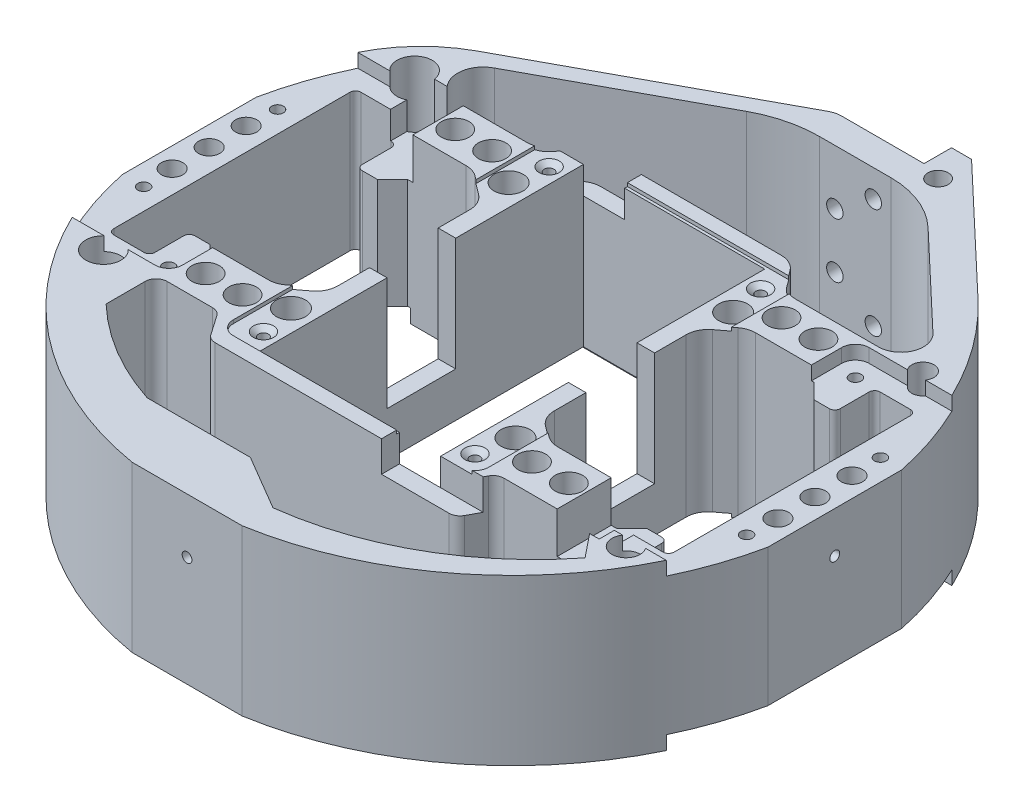
from build123d import *

# Parameters (mm, degrees)
SKETCH1_R             = 2.356484411
SKETCH1_R_2           = 3.356538595
SKETCH1_R_3           = 3.175
SKETCH1_R_4           = 4.064709562
SKETCH1_R_5           = 2.555437721
SKETCH1_R_6           = 3.242334338
SKETCH1_R_7           = 2.462755239
BOSS_EXTRUDE1_DEPTH   = 38.1
SKETCH2_W             = 4.064
SKETCH2_H             = 15.875
CUT_EXTRUDE1_DEPTH    = 26.9875
CUT_EXTRUDE2_DEPTH    = 3.175
SKETCH4_R             = 1.35255
CUT_EXTRUDE3_DEPTH    = 6.35
SKETCH5_W             = 10.883984269
SKETCH5_H             = 18.972538828
CUT_EXTRUDE4_DEPTH    = 6.35
CUT_EXTRUDE7_DEPTH    = 7.112
CUT_EXTRUDE8_REACH    = 153.334
SKETCH10_R            = 1.89865
SKETCH11_R            = 1.1303
CUT_EXTRUDE9_DEPTH    = 9.525
SKETCH12_R            = 1.1303
CUT_EXTRUDE10_DEPTH   = 9.525
CUT_EXTRUDE11_DEPTH   = 0.79375
SKETCH6_R             = 1.1303
CUT_EXTRUDE5_DEPTH    = 12.7
CHAMFER1_SIZE         = 1.19507
CHAMFER1_SIZE2        = 1.038858502
CHAMFER1_PART_2_SIZE  = 1.19507
CHAMFER1_PART_2_SIZE2 = 1.038858502
CHAMFER1_PART_3_SIZE  = 1.19507
CHAMFER1_PART_3_SIZE2 = 1.038858502
CHAMFER1_PART_4_SIZE  = 1.19507
CHAMFER1_PART_4_SIZE2 = 1.038858502
CHAMFER2_SIZE         = 1.19507
CHAMFER2_SIZE2        = 1.038858502
CHAMFER2_PART_2_SIZE  = 1.19507
CHAMFER2_PART_2_SIZE2 = 1.038858502
CHAMFER2_PART_3_SIZE  = 1.19507
CHAMFER2_PART_3_SIZE2 = 1.038858502
CHAMFER2_PART_4_SIZE  = 1.19507
CHAMFER2_PART_4_SIZE2 = 1.038858502


with BuildPart() as part:
    # Sketch1 → Boss-Extrude1 (new body)
    with BuildSketch(Plane(origin=(0, 0, 0), x_dir=(1, 0, 0), z_dir=(0, 1, 0))):
        with BuildLine():
            Line((-74.6125, 15.473036022), (-74.6125, -15.473036022))
            ThreePointArc((-74.6125, -15.473036022), (-52.874683743, -54.86991725), (-12.7, -75.134213245))
            Line((-12.7, -75.134213245), (12.7, -75.134213245))
            ThreePointArc((12.7, -75.134213245), (52.874683743, -54.86991725), (74.6125, -15.473036022))
            Line((74.6125, -15.473036022), (74.6125, 15.473036022))
            ThreePointArc((74.6125, 15.473036022), (66.568680107, 37.081677804), (52.429845716, 55.295128883))
            Line((52.429845716, 55.295128883), (23.6855, 82.55))
            Line((23.6855, 82.55), (19.05, 82.55))
            Line((19.05, 82.55), (19.05, 76.2))
            Line((19.05, 76.2), (0, 76.2))
            ThreePointArc((0, 76.2), (-1.309576606, 76.036760248), (-2.539006662, 75.557031324))
            Line((-2.539006662, 75.557031324), (-55.150410299, 47.084918442))
            ThreePointArc((-55.150410299, 47.084918442), (-63.168001103, 40.936392006), (-68.874977996, 32.598733198))
            ThreePointArc((-68.874977996, 32.598733198), (-72.252933929, 24.206477205), (-74.6125, 15.473036022))
        make_face()
        with Locations((23.6855, 74.812542953)):
            Circle(SKETCH1_R, mode=Mode.SUBTRACT)
        with Locations((-25.953983408, 25.159074147)):
            Circle(SKETCH1_R_2, mode=Mode.SUBTRACT)
        with Locations((-41.987680119, 28.850105121)):
            Circle(SKETCH1_R_3, mode=Mode.SUBTRACT)
        with Locations((41.987680119, 28.850105121)):
            Circle(SKETCH1_R_3, mode=Mode.SUBTRACT)
        with Locations((-41.987680119, -28.850105121)):
            Circle(SKETCH1_R_3, mode=Mode.SUBTRACT)
        with Locations((41.987680119, -28.850105121)):
            Circle(SKETCH1_R_3, mode=Mode.SUBTRACT)
        with Locations((-33.451838253, 28.850105121)):
            Circle(SKETCH1_R_3, mode=Mode.SUBTRACT)
        with Locations((33.451838253, 28.850105121)):
            Circle(SKETCH1_R_3, mode=Mode.SUBTRACT)
        with Locations((-33.451838253, -28.850105121)):
            Circle(SKETCH1_R_3, mode=Mode.SUBTRACT)
        with Locations((33.451838253, -28.850105121)):
            Circle(SKETCH1_R_3, mode=Mode.SUBTRACT)
        with Locations((-58.499626731, 35.97459363)):
            Circle(SKETCH1_R_4, mode=Mode.SUBTRACT)
        with Locations((60.460006294, 34.52310187)):
            Circle(SKETCH1_R_5, mode=Mode.SUBTRACT)
        with Locations((-58.499626731, -35.97459363)):
            Circle(SKETCH1_R_4, mode=Mode.SUBTRACT)
        with Locations((61.236723994, -34.882223147)):
            Circle(SKETCH1_R_6, mode=Mode.SUBTRACT)
        with Locations((25.953983408, 25.159074147)):
            Circle(SKETCH1_R_2, mode=Mode.SUBTRACT)
        with Locations((25.953983408, -25.159074147)):
            Circle(SKETCH1_R_2, mode=Mode.SUBTRACT)
        with Locations((-25.953983408, -25.159074147)):
            Circle(SKETCH1_R_2, mode=Mode.SUBTRACT)
        with Locations((70.02564652, 8.562540674)):
            Circle(SKETCH1_R_7, mode=Mode.SUBTRACT)
        with Locations((-70.02564652, 8.562540674)):
            Circle(SKETCH1_R_7, mode=Mode.SUBTRACT)
        with Locations((70.02564652, -8.562540674)):
            Circle(SKETCH1_R_7, mode=Mode.SUBTRACT)
        with Locations((-70.02564652, -8.562540674)):
            Circle(SKETCH1_R_7, mode=Mode.SUBTRACT)
        with Locations((-70.02564652, 0)):
            Circle(SKETCH1_R_7, mode=Mode.SUBTRACT)
        with Locations((70.02564652, 0)):
            Circle(SKETCH1_R_7, mode=Mode.SUBTRACT)
        Polygon((20.955, 37.465), (-20.955, 37.465), (-20.955, 0), (-20.955, -37.465), (20.955, -37.465), (20.955, 0), align=None, mode=Mode.SUBTRACT)
        with BuildLine():
            Line((-53.975, 19.3675), (-50.4825, 19.3675))
            Line((-50.4825, 19.3675), (-46.99, 22.86))
            Line((-46.99, 22.86), (-33.451838253, 22.86))
            ThreePointArc((-33.451838253, 22.86), (-31.838145049, 22.596886364), (-30.391611171, 21.834800884))
            Line((-30.391611171, 21.834800884), (-27.038772918, 19.304356919))
            ThreePointArc((-27.038772918, 19.304356919), (-25.551893581, 17.514555641), (-25.019, 15.249556036))
            Line((-25.019, 15.249556036), (-25.019, 0))
            Line((-25.019, 0), (-25.019, -15.249556036))
            ThreePointArc((-25.019, -15.249556036), (-25.551893581, -17.514555641), (-27.038772918, -19.304356919))
            Line((-27.038772918, -19.304356919), (-30.391611171, -21.834800884))
            ThreePointArc((-30.391611171, -21.834800884), (-31.838145049, -22.596886364), (-33.451838253, -22.86))
            Line((-33.451838253, -22.86), (-46.99, -22.86))
            Line((-46.99, -22.86), (-50.4825, -19.3675))
            Line((-50.4825, -19.3675), (-53.975, -19.3675))
            ThreePointArc((-53.975, -19.3675), (-54.873025612, -19.739474388), (-55.245, -20.6375))
            Line((-55.245, -20.6375), (-55.245, -27.305))
            ThreePointArc((-55.245, -27.305), (-55.616974388, -28.203025612), (-56.515, -28.575))
            Line((-56.515, -28.575), (-63.5, -28.575))
            ThreePointArc((-63.5, -28.575), (-64.398025612, -28.203025612), (-64.77, -27.305))
            Line((-64.77, -27.305), (-64.77, 27.305))
            ThreePointArc((-64.77, 27.305), (-64.398025612, 28.203025612), (-63.5, 28.575))
            Line((-63.5, 28.575), (-56.515, 28.575))
            ThreePointArc((-56.515, 28.575), (-55.616974388, 28.203025612), (-55.245, 27.305))
            Line((-55.245, 27.305), (-55.245, 20.6375))
            ThreePointArc((-55.245, 20.6375), (-54.873025612, 19.739474388), (-53.975, 19.3675))
        make_face(mode=Mode.SUBTRACT)
        with BuildLine():
            Line((64.77, 27.305), (64.77, -27.305))
            ThreePointArc((64.77, -27.305), (64.398025612, -28.203025612), (63.5, -28.575))
            Line((63.5, -28.575), (56.515, -28.575))
            ThreePointArc((56.515, -28.575), (55.616974388, -28.203025612), (55.245, -27.305))
            Line((55.245, -27.305), (55.245, -20.6375))
            ThreePointArc((55.245, -20.6375), (54.873025612, -19.739474388), (53.975, -19.3675))
            Line((53.975, -19.3675), (50.4825, -19.3675))
            Line((50.4825, -19.3675), (46.99, -22.86))
            Line((46.99, -22.86), (33.451838253, -22.86))
            ThreePointArc((33.451838253, -22.86), (31.838145049, -22.596886364), (30.391611171, -21.834800884))
            Line((30.391611171, -21.834800884), (27.038772918, -19.304356919))
            ThreePointArc((27.038772918, -19.304356919), (25.551893581, -17.514555641), (25.019, -15.249556036))
            Line((25.019, -15.249556036), (25.019, 0))
            Line((25.019, 0), (25.019, 15.249556036))
            ThreePointArc((25.019, 15.249556036), (25.551893581, 17.514555641), (27.038772918, 19.304356919))
            Line((27.038772918, 19.304356919), (30.391611171, 21.834800884))
            ThreePointArc((30.391611171, 21.834800884), (31.838145049, 22.596886364), (33.451838253, 22.86))
            Line((33.451838253, 22.86), (46.99, 22.86))
            Line((46.99, 22.86), (50.4825, 19.3675))
            Line((50.4825, 19.3675), (53.975, 19.3675))
            ThreePointArc((53.975, 19.3675), (54.873025612, 19.739474388), (55.245, 20.6375))
            Line((55.245, 20.6375), (55.245, 27.305))
            ThreePointArc((55.245, 27.305), (55.616974388, 28.203025612), (56.515, 28.575))
            Line((56.515, 28.575), (63.5, 28.575))
            ThreePointArc((63.5, 28.575), (64.398025612, 28.203025612), (64.77, 27.305))
        make_face(mode=Mode.SUBTRACT)
        with BuildLine():
            Line((-20.845950883, 41.338131188), (0, 41.338131188))
            Line((0, 41.338131188), (20.900876069, 41.338131188))
            ThreePointArc((20.900876069, 41.338131188), (23.189592711, 40.793346302), (24.987420284, 39.275838327))
            Line((24.987420284, 39.275838327), (27.196988383, 36.283666683))
            ThreePointArc((27.196988383, 36.283666683), (28.994815956, 34.766158708), (31.283532598, 34.221373822))
            Line((31.283532598, 34.221373822), (50.45628088, 34.221373822))
            ThreePointArc((50.45628088, 34.221373822), (55.31708187, 37.516208085), (54.056832983, 43.251632379))
            Line((54.056832983, 43.251632379), (32.348707377, 63.834886263))
            ThreePointArc((32.348707377, 63.834886263), (25.730530949, 68.068574663), (18.014985698, 69.550039535))
            Line((18.014985698, 69.550039535), (1.55163213, 69.550039535))
            ThreePointArc((1.55163213, 69.550039535), (-5.413950327, 68.681774216), (-11.953236682, 66.130116403))
            Line((-11.953236682, 66.130116403), (-49.707341043, 45.69844101))
            ThreePointArc((-49.707341043, 45.69844101), (-52.830230484, 39.073656263), (-47.091531492, 34.52310187))
            Line((-47.091531492, 34.52310187), (-31.086999544, 34.52310187))
            ThreePointArc((-31.086999544, 34.52310187), (-28.840846685, 35.046656179), (-27.057679262, 36.509402133))
            Line((-27.057679262, 36.509402133), (-24.875271165, 39.351830925))
            ThreePointArc((-24.875271165, 39.351830925), (-23.092103742, 40.814576878), (-20.845950883, 41.338131188))
        make_face(mode=Mode.SUBTRACT)
        with BuildLine():
            Line((-23.854336738, -60.495536567), (0, -60.495536567))
            Line((0, -60.495536567), (12.7, -67.96894498))
            ThreePointArc((12.7, -67.96894498), (38.322472705, -59.497281046), (58.80689112, -41.928308409))
            Line((58.80689112, -41.928308409), (54.275996481, -36.293661738))
            ThreePointArc((54.275996481, -36.293661738), (53.394000982, -35.594661364), (52.296567671, -35.345346879))
            Line((52.296567671, -35.345346879), (33.457769344, -35.345346879))
            ThreePointArc((33.457769344, -35.345346879), (32.159314658, -35.702317921), (31.225829045, -36.672893786))
            Line((31.225829045, -36.672893786), (29.270713217, -40.271962344))
            ThreePointArc((29.270713217, -40.271962344), (28.337227604, -41.242538208), (27.038772918, -41.599509251))
            Line((27.038772918, -41.599509251), (-27.038772918, -41.599509251))
            ThreePointArc((-27.038772918, -41.599509251), (-28.216614381, -41.30990688), (-29.125868694, -40.507138769))
            Line((-29.125868694, -40.507138769), (-32.269685191, -35.97459363))
            ThreePointArc((-32.269685191, -35.97459363), (-33.178939505, -35.171825519), (-34.356780968, -34.882223147))
            Line((-34.356780968, -34.882223147), (-44.859278162, -34.882223147))
            ThreePointArc((-44.859278162, -34.882223147), (-46.655329386, -35.626171923), (-47.399278162, -37.422223147))
            Line((-47.399278162, -37.422223147), (-47.399278162, -46.454771748))
            ThreePointArc((-47.399278162, -46.454771748), (-36.419314032, -54.804107481), (-23.854336738, -60.495536567))
        make_face(mode=Mode.SUBTRACT)
    extrude(amount=BOSS_EXTRUDE1_DEPTH)

    # Sketch2 → Cut-Extrude1 (cut)
    with BuildSketch(Plane(origin=(0, 38.1, 0), x_dir=(1, 0, 0), z_dir=(0, 1, 0))):
        with Locations((-22.987, 0)):
            Rectangle(SKETCH2_W, SKETCH2_H)
        with Locations((22.987, 0)):
            Rectangle(SKETCH2_W, SKETCH2_H)
    extrude(amount=-CUT_EXTRUDE1_DEPTH, mode=Mode.SUBTRACT)

    # Sketch3 → Cut-Extrude2 (cut)
    with BuildSketch(Plane(origin=(0, 38.1, 0), x_dir=(1, 0, 0), z_dir=(0, 1, 0))):
        with BuildLine():
            Line((-49.53, 33.02), (-80.011418761, 33.02))
            Line((-80.011418761, 33.02), (-80.011418761, -33.02))
            Line((-80.011418761, -33.02), (-49.53, -33.02))
            ThreePointArc((-49.53, -33.02), (-47.28493597, -32.09006403), (-46.355, -29.845))
            Line((-46.355, -29.845), (-46.355, 29.845))
            ThreePointArc((-46.355, 29.845), (-47.28493597, 32.09006403), (-49.53, 33.02))
        make_face()
        with BuildLine():
            Line((80.011418761, 33.02), (80.011418761, -33.02))
            Line((80.011418761, -33.02), (49.53, -33.02))
            ThreePointArc((49.53, -33.02), (47.28493597, -32.09006403), (46.355, -29.845))
            Line((46.355, -29.845), (46.355, 29.845))
            ThreePointArc((46.355, 29.845), (47.28493597, 32.09006403), (49.53, 33.02))
            Line((49.53, 33.02), (80.011418761, 33.02))
        make_face()
    cut_extrude2 = extrude(amount=-CUT_EXTRUDE2_DEPTH, mode=Mode.SUBTRACT)

    # Sketch4 → Cut-Extrude3 (cut)
    with BuildSketch(Plane(origin=(0, 34.925, 0), x_dir=(1, 0, 0), z_dir=(0, 1, 0))):
        with Locations((-50.8, 28.575)):
            Circle(SKETCH4_R)
        with Locations((-69.69125, 15.473036022)):
            Circle(SKETCH4_R)
        with Locations((69.69125, 15.473036022)):
            Circle(SKETCH4_R)
        with Locations((50.8, 28.575)):
            Circle(SKETCH4_R)
        with Locations((50.8, -28.575)):
            Circle(SKETCH4_R)
        with Locations((69.69125, -15.473036022)):
            Circle(SKETCH4_R)
        with Locations((-69.69125, -15.473036022)):
            Circle(SKETCH4_R)
        with Locations((-50.8, -28.575)):
            Circle(SKETCH4_R)
    cut_extrude3 = extrude(amount=-CUT_EXTRUDE3_DEPTH, mode=Mode.SUBTRACT)

    # Mirror1: Cut-Extrude2, Cut-Extrude3 across plane
    add(cut_extrude2.mirror(Plane.ZX.offset(19.05)), mode=Mode.SUBTRACT)
    add(cut_extrude3.mirror(Plane.ZX.offset(19.05)), mode=Mode.SUBTRACT)

    # Sketch5 → Cut-Extrude4 (cut, symmetric)
    with BuildSketch(Plane(origin=(0, 34.925, 0), x_dir=(1, 0, 0), z_dir=(0, 1, 0))):
        with Locations((-51.228437622, 27.038665643)):
            Rectangle(SKETCH5_W, SKETCH5_H)
        with Locations((51.228437622, -27.038665643)):
            Rectangle(SKETCH5_W, SKETCH5_H)
    extrude(amount=CUT_EXTRUDE4_DEPTH, both=True, mode=Mode.SUBTRACT)

    # Sketch9 → Cut-Extrude7 (cut)
    with BuildSketch(Plane(origin=(0, 38.1, 0), x_dir=(1, 0, 0), z_dir=(0, 1, 0))):
        Polygon((-20.955, 34.326574642), (-11.43, 34.326574642), (-11.43, 45.377122901), (-20.955, 45.377122901), (-29.461924573, 45.377122901), (-29.461924573, 37.465), (-20.955, 37.465), align=None)
        Polygon((20.955, -34.326574642), (11.43, -34.326574642), (11.43, -45.377122901), (20.955, -45.377122901), (32.397962239, -45.377122901), (32.397962239, -37.465), (20.955, -37.465), align=None)
    extrude(amount=-CUT_EXTRUDE7_DEPTH, mode=Mode.SUBTRACT)

    # Sketch10 → Cut-Extrude8 (cut, up to next)
    with BuildSketch(Plane(origin=(0, 0, -76.2), x_dir=(-1, 0, 0), z_dir=(0, 0, -1)), mode=Mode.PRIVATE) as cut_extrude8_sk1:
        with Locations((-13.97, 31.75)):
            Circle(SKETCH10_R)
    cut_extrude8_tool1 = extrude(cut_extrude8_sk1.sketch, amount=-CUT_EXTRUDE8_REACH, mode=Mode.PRIVATE) & part.part
    add(cut_extrude8_tool1.solids().sort_by_distance((13.97, 31.75, -76.2))[0], mode=Mode.SUBTRACT)
    # Sketch10 → Cut-Extrude8 (cut, up to next)
    with BuildSketch(Plane(origin=(0, 0, -76.2), x_dir=(-1, 0, 0), z_dir=(0, 0, -1)), mode=Mode.PRIVATE) as cut_extrude8_sk2:
        with Locations((-5.08, 25.4)):
            Circle(SKETCH10_R)
    cut_extrude8_tool2 = extrude(cut_extrude8_sk2.sketch, amount=-CUT_EXTRUDE8_REACH, mode=Mode.PRIVATE) & part.part
    add(cut_extrude8_tool2.solids().sort_by_distance((5.08, 25.4, -76.2))[0], mode=Mode.SUBTRACT)
    # Sketch10 → Cut-Extrude8 (cut, up to next)
    with BuildSketch(Plane(origin=(0, 0, -76.2), x_dir=(-1, 0, 0), z_dir=(0, 0, -1)), mode=Mode.PRIVATE) as cut_extrude8_sk3:
        with Locations((-5.08, 12.7)):
            Circle(SKETCH10_R)
    cut_extrude8_tool3 = extrude(cut_extrude8_sk3.sketch, amount=-CUT_EXTRUDE8_REACH, mode=Mode.PRIVATE) & part.part
    add(cut_extrude8_tool3.solids().sort_by_distance((5.08, 12.7, -76.2))[0], mode=Mode.SUBTRACT)
    # Sketch10 → Cut-Extrude8 (cut, up to next)
    with BuildSketch(Plane(origin=(0, 0, -76.2), x_dir=(-1, 0, 0), z_dir=(0, 0, -1)), mode=Mode.PRIVATE) as cut_extrude8_sk4:
        with Locations((-13.97, 6.35)):
            Circle(SKETCH10_R)
    cut_extrude8_tool4 = extrude(cut_extrude8_sk4.sketch, amount=-CUT_EXTRUDE8_REACH, mode=Mode.PRIVATE) & part.part
    add(cut_extrude8_tool4.solids().sort_by_distance((13.97, 6.35, -76.2))[0], mode=Mode.SUBTRACT)

    # Sketch11 → Cut-Extrude9 (cut)
    with BuildSketch(Plane.ZY.offset(74.6125)):
        with Locations((0, 25.4)):
            Circle(SKETCH11_R)
    cut_extrude9 = extrude(amount=-CUT_EXTRUDE9_DEPTH, mode=Mode.SUBTRACT)

    # Mirror10: Cut-Extrude9 across plane
    add(cut_extrude9.mirror(Plane.ZY), mode=Mode.SUBTRACT)

    # Sketch12 → Cut-Extrude10 (cut)
    with BuildSketch(Plane.XY.offset(75.134213245)):
        with Locations((0, 25.4)):
            Circle(SKETCH12_R)
    extrude(amount=-CUT_EXTRUDE10_DEPTH, mode=Mode.SUBTRACT)

    # Sketch13 → Cut-Extrude11 (cut)
    with BuildSketch(Plane(origin=(0, 38.1, 0), x_dir=(1, 0, 0), z_dir=(0, 1, 0))):
        with BuildLine():
            Line((-26.3525, -38.1), (26.3525, -38.1))
            ThreePointArc((26.3525, -38.1), (28.59756403, -37.17006403), (29.5275, -34.925))
            Line((29.5275, -34.925), (29.5275, 34.925))
            ThreePointArc((29.5275, 34.925), (28.59756403, 37.17006403), (26.3525, 38.1))
            Line((26.3525, 38.1), (-26.3525, 38.1))
            ThreePointArc((-26.3525, 38.1), (-28.59756403, 37.17006403), (-29.5275, 34.925))
            Line((-29.5275, 34.925), (-29.5275, -34.925))
            ThreePointArc((-29.5275, -34.925), (-28.59756403, -37.17006403), (-26.3525, -38.1))
        make_face()
    cut_extrude11 = extrude(amount=-CUT_EXTRUDE11_DEPTH, mode=Mode.SUBTRACT)

    # Mirror11: Cut-Extrude11 across plane
    add(cut_extrude11.mirror(Plane.ZX.offset(19.05)), mode=Mode.SUBTRACT)

    # Sketch6 → Cut-Extrude5 (cut)
    with BuildSketch(Plane.XZ):
        with Locations((-24.4475, 33.02)):
            Circle(SKETCH6_R)
        with Locations((24.4475, 33.02)):
            Circle(SKETCH6_R)
        with Locations((24.4475, -33.02)):
            Circle(SKETCH6_R)
        with Locations((-24.4475, -33.02)):
            Circle(SKETCH6_R)
    cut_extrude5 = extrude(amount=-CUT_EXTRUDE5_DEPTH, mode=Mode.SUBTRACT)

    # Mirror9: Cut-Extrude5 across plane
    add(cut_extrude5.mirror(Plane.ZX.offset(19.05)), mode=Mode.SUBTRACT)

    # Chamfer1
    chamfer1_edges = [part.edges().sort_by_distance(p)[0] for p in [
        (-25.5778, 0.79375, 33.02),
    ]]
    chamfer1_side = [part.faces().sort_by_distance(p)[0] for p in [
        (-25.5778, 6.746875, 33.02),
    ]]
    chamfer(chamfer1_edges, length=CHAMFER1_SIZE, length2=CHAMFER1_SIZE2, reference=chamfer1_side[0])

    # Chamfer1 part 2
    chamfer1_part_2_edges = [part.edges().sort_by_distance(p)[0] for p in [
        (23.3172, 0.79375, 33.02),
    ]]
    chamfer1_part_2_side = [part.faces().sort_by_distance(p)[0] for p in [
        (23.3172, 6.746875, 33.02),
    ]]
    chamfer(chamfer1_part_2_edges, length=CHAMFER1_PART_2_SIZE, length2=CHAMFER1_PART_2_SIZE2, reference=chamfer1_part_2_side[0])

    # Chamfer1 part 3
    chamfer1_part_3_edges = [part.edges().sort_by_distance(p)[0] for p in [
        (23.3172, 0.79375, -33.02),
    ]]
    chamfer1_part_3_side = [part.faces().sort_by_distance(p)[0] for p in [
        (23.3172, 6.746875, -33.02),
    ]]
    chamfer(chamfer1_part_3_edges, length=CHAMFER1_PART_3_SIZE, length2=CHAMFER1_PART_3_SIZE2, reference=chamfer1_part_3_side[0])

    # Chamfer1 part 4
    chamfer1_part_4_edges = [part.edges().sort_by_distance(p)[0] for p in [
        (-25.5778, 0.79375, -33.02),
    ]]
    chamfer1_part_4_side = [part.faces().sort_by_distance(p)[0] for p in [
        (-25.5778, 6.746875, -33.02),
    ]]
    chamfer(chamfer1_part_4_edges, length=CHAMFER1_PART_4_SIZE, length2=CHAMFER1_PART_4_SIZE2, reference=chamfer1_part_4_side[0])

    # Chamfer2
    chamfer2_edges = [part.edges().sort_by_distance(p)[0] for p in [
        (-25.5778, 37.30625, 33.02),
    ]]
    chamfer2_side = [part.faces().sort_by_distance(p)[0] for p in [
        (-22.225601427, 37.30625, 26.418667692),
    ]]
    chamfer(chamfer2_edges, length=CHAMFER2_SIZE, length2=CHAMFER2_SIZE2, reference=chamfer2_side[0])

    # Chamfer2 part 2
    chamfer2_part_2_edges = [part.edges().sort_by_distance(p)[0] for p in [
        (23.3172, 37.30625, 33.02),
    ]]
    chamfer2_part_2_side = [part.faces().sort_by_distance(p)[0] for p in [
        (24.60625, 37.30625, 37.157532764),
    ]]
    chamfer(chamfer2_part_2_edges, length=CHAMFER2_PART_2_SIZE, length2=CHAMFER2_PART_2_SIZE2, reference=chamfer2_part_2_side[0])

    # Chamfer2 part 3
    chamfer2_part_3_edges = [part.edges().sort_by_distance(p)[0] for p in [
        (23.3172, 37.30625, -33.02),
    ]]
    chamfer2_part_3_side = [part.faces().sort_by_distance(p)[0] for p in [
        (22.042659142, 37.30625, -26.097748082),
    ]]
    chamfer(chamfer2_part_3_edges, length=CHAMFER2_PART_3_SIZE, length2=CHAMFER2_PART_3_SIZE2, reference=chamfer2_part_3_side[0])

    # Chamfer2 part 4
    chamfer2_part_4_edges = [part.edges().sort_by_distance(p)[0] for p in [
        (-25.5778, 37.30625, -33.02),
    ]]
    chamfer2_part_4_side = [part.faces().sort_by_distance(p)[0] for p in [
        (-29.220032764, 37.30625, -27.975519772),
    ]]
    chamfer(chamfer2_part_4_edges, length=CHAMFER2_PART_4_SIZE, length2=CHAMFER2_PART_4_SIZE2, reference=chamfer2_part_4_side[0])


solid = part.part
